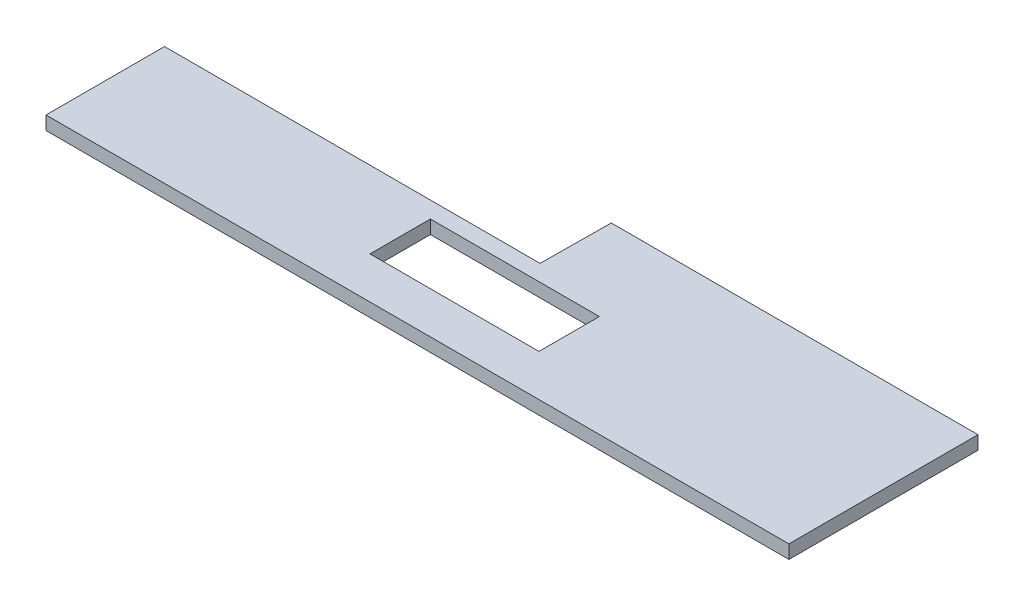
from build123d import *

# Parameters (mm, degrees)
SKETCH1_W           = 25.012643909
SKETCH1_H           = 8.941938647
BOSS_EXTRUDE1_DEPTH = 2


with BuildPart() as part:
    # Sketch1 → Boss-Extrude1 (new body)
    with BuildSketch(Plane(origin=(0, 0, 0), x_dir=(1, 0, 0), z_dir=(0, 1, 0))):
        Polygon((12.244705421, 9.289945609), (66.543678684, 9.289945609), (66.543678684, -18.710054391), (-43.456321316, -18.710054391), (-43.456321316, -1.162360163), (12.148339373, -1.162360163), align=None)
        with Locations((10.851931882, -8.063685007)):
            Rectangle(SKETCH1_W, SKETCH1_H, mode=Mode.SUBTRACT)
    extrude(amount=BOSS_EXTRUDE1_DEPTH)


solid = part.part
